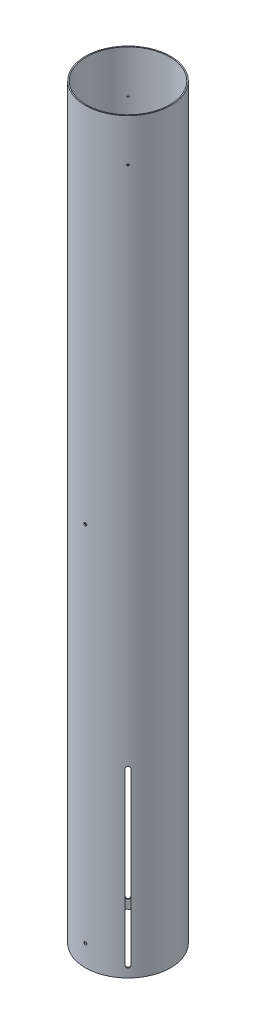
from build123d import *

# Parameters (mm, degrees)
SKETCH1_R           = 50.8
SKETCH1_R_2         = 49.53
BOSS_EXTRUDE1_DEPTH = 889
CUT_EXTRUDE1_DEPTH  = 152.4
CIRPATTERN1_COUNT   = 4
SKETCH3_R           = 1.7653
CUT_EXTRUDE2_DEPTH  = 11.684
SKETCH4_R           = 1.0922
CUT_EXTRUDE3_DEPTH  = 25.4
CIRPATTERN2_COUNT   = 2


with BuildPart() as part:
    # Sketch1 → Boss-Extrude1 (new body)
    with BuildSketch(Plane(origin=(0, 0, 0), x_dir=(1, 0, 0), z_dir=(0, 1, 0))):
        with Locations(Location((0, 0, 0), (0, 0, 270))):
            Circle(SKETCH1_R)
        with Locations(Location((0, 0, 0), (0, 0, 270))):
            Circle(SKETCH1_R_2, mode=Mode.SUBTRACT)
    extrude(amount=BOSS_EXTRUDE1_DEPTH)

    # Sketch2 → Cut-Extrude1 (cut)
    with BuildSketch(Plane(origin=(10.001989034, 1243.355570529, -188.138382022), x_dir=(0, 1, 0), z_dir=(0.7071067811865634, 0, -0.7071067811865316))):
        with BuildLine():
            Line((-1230.655570529, 128.342701458), (-1027.455570529, 128.342701458))
            ThreePointArc((-1027.455570529, 128.342701458), (-1025.074320529, 125.961451458), (-1027.455570529, 123.580201458))
            Line((-1027.455570529, 123.580201458), (-1230.655570529, 123.580201458))
            ThreePointArc((-1230.655570529, 123.580201458), (-1233.036820529, 125.961451458), (-1230.655570529, 128.342701458))
        make_face()
    cut_extrude1 = extrude(amount=-CUT_EXTRUDE1_DEPTH, mode=Mode.SUBTRACT)

    # CirPattern1: Cut-Extrude1 ×4 about axis
    cirpattern1_axis = Axis((0, 0, 0), (0, 1, 0))
    for i in range(1, CIRPATTERN1_COUNT):
        add(cut_extrude1.rotate(cirpattern1_axis, i * 360 / CIRPATTERN1_COUNT), mode=Mode.SUBTRACT)

    # Sketch3 → Cut-Extrude2 (cut)
    with BuildSketch(Plane(origin=(271.091614788, 1243.355570529, 52.3875), x_dir=(-1, 0, 0), z_dir=(0, 0, 1))):
        with Locations(Location((271.091614788, 1217.955570529, 0), (0, 0, 180))):
            Circle(SKETCH3_R)
        with Locations(Location((271.091614788, 786.155570529, 0), (0, 0, 180))):
            Circle(SKETCH3_R)
    extrude(amount=-CUT_EXTRUDE2_DEPTH, mode=Mode.SUBTRACT)

    # Sketch4 → Cut-Extrude3 (cut)
    with BuildSketch(Plane(origin=(120.58027232, 708.404628356, -48.738223352), x_dir=(-0.7071067811865634, 2.660214291711019e-15, 0.7071067811865317), z_dir=(0.7071067811865317, -1.2152886494782433e-14, 0.7071067811865634))):
        with Locations(Location((119.72625647, -129.795371644, 0), (0, 0, 180))):
            Circle(SKETCH4_R)
    cut_extrude3 = extrude(amount=-CUT_EXTRUDE3_DEPTH, mode=Mode.SUBTRACT)

    # CirPattern2: Cut-Extrude3 ×2 about axis
    cirpattern2_axis = Axis((0, 889, 0), (0, -1, 0))
    for i in range(1, CIRPATTERN2_COUNT):
        add(cut_extrude3.rotate(cirpattern2_axis, i * 360 / CIRPATTERN2_COUNT), mode=Mode.SUBTRACT)


solid = part.part
